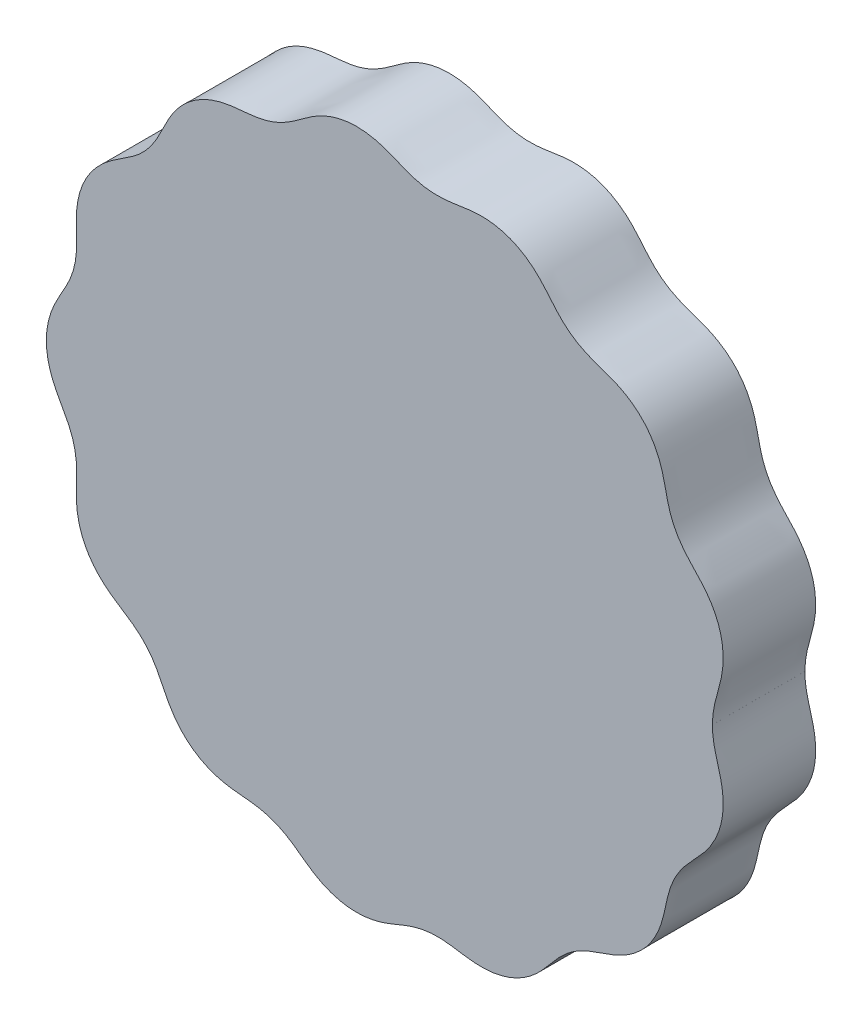
from build123d import *

# Parameters (mm, degrees)
BOSS_EXTRUDE1_DEPTH = 10


with BuildPart() as part:
    # Sketch1 → Boss-Extrude1 (new body)
    with BuildSketch(Plane.XY):
        with BuildLine():
            add(Edge.make_bspline(
                [(35, 0), (35, -0.049310934), (35.000826925, -0.123549041), (35.00358334, -0.260905708), (35.011001765, -0.443866873), (35.02168003, -0.615246909), (35.038822352, -0.820246291), (35.064644021, -1.054225265), (35.104389094, -1.344688824), (35.163372924, -1.692203356), (35.246948475, -2.094474225), (35.358433569, -2.55079151), (35.480657747, -3.004163087), (35.634642353, -3.552998444), (35.812720375, -4.19930319), (35.990573811, -4.949837651), (36.127871975, -5.811262759), (36.182763873, -6.633837248), (36.162995201, -7.409659641), (36.061865068, -8.301480074), (35.875566573, -9.131461485), (35.600274681, -9.936302866), (35.241274265, -10.705998089), (34.906867041, -11.297453714), (34.471313565, -11.949104091), (33.918976342, -12.645450647), (33.24636376, -13.375251593), (32.486194193, -14.16540454), (31.729556574, -15.049165196), (31.046122514, -16.073879372), (30.531343894, -17.194682801), (30.182801414, -18.374420877), (29.944004061, -19.511701744), (29.714374148, -20.584179661), (29.295803858, -22.028148088), (28.462175689, -23.758619693), (27.039511715, -25.411663684), (25.220785614, -26.552164252), (23.632554765, -27.156246313), (22.308241317, -27.596309207), (21.122642737, -28.048878518), (19.998404102, -28.665974936), (18.990362365, -29.469448636), (18.17926367, -30.310264933), (17.506810894, -31.116961152), (16.774956468, -32.003835501), (15.910810759, -32.910989873), (14.603968244, -33.956795362), (12.973977424, -34.758694982), (11.172275828, -35.168753031), (9.452445917, -35.168946806), (8.180676827, -35.007322448), (7.060772067, -34.824590111), (6.077839965, -34.700136729), (4.92526664, -34.654901605), (3.611717568, -34.785681451), (2.34898034, -35.144972521), (1.151468871, -35.643176313), (0.11112449, -36.077304048), (-0.791447095, -36.396834046), (-2.145904167, -36.746914748), (-3.98951328, -36.899860547), (-5.867576144, -36.569631631), (-7.608410698, -35.760261886), (-8.856327652, -34.923335177), (-9.733039987, -34.264800627), (-10.676569221, -33.585684911), (-11.741606641, -32.968376824), (-12.889652144, -32.516976577), (-14.091231923, -32.248027474), (-15.246626723, -32.116451018), (-16.339545407, -32.031422114), (-17.493902089, -31.890723419), (-18.692749484, -31.615334014), (-20.222356026, -31.027358158), (-21.761540735, -30.015940811), (-23.10712517, -28.570457222), (-24.107018635, -26.790727225), (-24.824578895, -25.167993152), (-25.628759836, -23.831611442), (-26.506880009, -22.828807468), (-27.377866045, -22.081755442), (-28.165338381, -21.523253444), (-29.117291307, -20.916900261), (-30.198918832, -20.207011214), (-31.269409842, -19.307551755), (-32.23169961, -18.159970842), (-32.949381231, -16.923233216), (-33.433253432, -15.648473233), (-33.695462895, -14.377812661), (-33.778365664, -13.150774619), (-33.752626295, -11.988801454), (-33.708623439, -10.893020119), (-33.732804458, -9.72956587), (-33.907551836, -8.510065169), (-34.272300595, -7.331799195), (-34.798722456, -6.220199301), (-35.375571547, -5.211611527), (-35.913027045, -4.255901727), (-36.551500379, -2.894765108), (-37.065135004, -1.044163044), (-37.081961548, 0.89324181), (-36.604044439, 2.743519909), (-35.992316197, 4.101262096), (-35.472668892, 5.045134004), (-34.893514715, 6.046838416), (-34.342047055, 7.156554542), (-33.945975846, 8.340330549), (-33.745354875, 9.575816636), (-33.706186832, 10.748767553), (-33.746008177, 11.844740972), (-33.779713502, 13.006251445), (-33.713735097, 14.234046359), (-33.472465306, 15.508780329), (-33.010585942, 16.791612729), (-32.323003578, 18.025433099), (-31.405631869, 19.164101965), (-30.376452217, 20.071047646), (-29.320648284, 20.789362643), (-28.359125221, 21.396424669), (-27.534006018, 21.961691411), (-26.64211418, 22.697115867), (-25.75330467, 23.666754111), (-25.052171961, 24.77089469), (-24.489024343, 25.934085453), (-23.99678217, 26.950841824), (-23.526827657, 27.795754618), (-22.736807023, 28.958901492), (-21.44808756, 30.292839058), (-19.815791171, 31.283258637), (-17.97322752, 31.821967087), (-16.483552658, 32.017713065), (-15.390573104, 32.105317493), (-14.234143791, 32.225772563), (-13.028559404, 32.475991946), (-11.872253588, 32.906226317), (-10.797594574, 33.507307672), (-9.847652658, 34.177822986), (-8.973112624, 34.838578492), (-8.013657651, 35.495538515), (-6.930904053, 36.079170913), (-5.393035326, 36.64508146), (-3.573447131, 36.897950298), (-1.618428071, 36.699809445), (0.303798345, 36.027939455), (1.91709374, 35.289608927), (3.408941719, 34.82571844), (4.736620881, 34.663014931), (5.881346244, 34.685859063), (6.831503524, 34.790818648), (7.94378724, 34.968034923), (9.22904619, 35.153537412), (10.634259731, 35.186555058), (12.124008649, 34.957296868), (13.488997174, 34.496606604), (14.703022495, 33.849803521), (15.74290263, 33.058847151), (16.615744669, 32.18408774), (17.536277891, 31.089607246), (18.448638028, 29.966488187), (19.593575718, 28.921637285), (20.928884162, 28.142170687), (22.10523455, 27.665349127), (23.222010494, 27.293956867), (24.245682165, 26.927775953), (25.608937462, 26.310183857), (27.19294663, 25.232247275), (28.459519151, 23.762767717), (29.293876673, 22.032863207), (29.713266114, 20.589019944), (29.94299122, 19.516612358), (30.181661325, 18.37927563), (30.529578603, 17.199393376), (31.043691667, 16.078271444), (31.726496935, 15.053149854), (32.482801355, 14.169074794), (33.242866577, 13.378834546), (34.030803992, 12.524455234), (34.778526462, 11.54802149), (35.33544245, 10.568085559), (35.717641828, 9.621618689), (35.948917034, 8.804336006), (36.080240473, 8.137642452), (36.162658402, 7.414653672), (36.182876804, 6.638849406), (36.12844469, 5.816231898), (35.99155664, 4.954749604), (35.786940236, 4.089807461), (35.571892127, 3.331954244), (35.387572999, 2.669628976), (35.248069215, 2.099447036), (35.152344118, 1.639434685), (35.086285678, 1.233977549), (35.044236756, 0.884014258), (35.022048081, 0.620168406), (35.011268303, 0.448861583), (35.003741135, 0.265908238), (35.000902541, 0.128549061), (35.000031086, 0.054310816), (35.0000015, 0.004999998)],
                knots=[0.079958514, 0.079958514, 0.079958514, 0.079958514, 0.079958514, 0.080801634, 0.081223194, 0.081644754, 0.082487873, 0.083330993, 0.084174113, 0.085017233, 0.086703472, 0.088389712, 0.090075951, 0.091762191, 0.09344843, 0.096577003, 0.099705577, 0.10283415, 0.105962723, 0.108400074, 0.110837425, 0.115712127, 0.118149426, 0.120586724, 0.123024022, 0.125461321, 0.129398917, 0.133336513, 0.13727411, 0.141211706, 0.146089501, 0.150967295, 0.154905156, 0.158843017, 0.162780878, 0.166718739, 0.176468314, 0.186217728, 0.193522586, 0.197175015, 0.200827444, 0.206276306, 0.211725169, 0.215495006, 0.219264842, 0.223034679, 0.226804515, 0.232014616, 0.237224717, 0.246973949, 0.252616416, 0.258258882, 0.261813328, 0.265367774, 0.268922221, 0.272476667, 0.27835693, 0.284237192, 0.28767307, 0.291108949, 0.294544827, 0.297980705, 0.307730653, 0.31747944, 0.321417046, 0.325354651, 0.329292257, 0.333229863, 0.338108644, 0.342987425, 0.346924808, 0.350862191, 0.354799575, 0.358736958, 0.363611799, 0.368486641, 0.378235835, 0.384925001, 0.391614167, 0.397677439, 0.40374071, 0.407204004, 0.410667298, 0.414130591, 0.417593885, 0.423418295, 0.429242704, 0.434117814, 0.438992924, 0.443866976, 0.448741029, 0.452679303, 0.456617576, 0.46055585, 0.464494124, 0.469372642, 0.474251159, 0.478187931, 0.482124702, 0.486061474, 0.489998246, 0.499748652, 0.509497693, 0.513365606, 0.517233518, 0.521101431, 0.524969343, 0.529986977, 0.535004611, 0.538942566, 0.542880521, 0.546818476, 0.550756431, 0.555630623, 0.560504815, 0.565379892, 0.57025497, 0.575829253, 0.581403536, 0.584991742, 0.588579947, 0.592168153, 0.595756358, 0.601569828, 0.607383298, 0.61085261, 0.614321922, 0.617791235, 0.621260547, 0.631010775, 0.64075969, 0.644697329, 0.648634967, 0.652572605, 0.656510243, 0.661390302, 0.66627036, 0.6702072, 0.67414404, 0.67808088, 0.68201772, 0.686892309, 0.691766898, 0.701516721, 0.708138352, 0.714759983, 0.720890149, 0.727020316, 0.73044972, 0.733879123, 0.737308527, 0.740737931, 0.746630466, 0.752523, 0.757398007, 0.762273014, 0.767232733, 0.772192452, 0.776087607, 0.779982761, 0.78777307, 0.792971131, 0.798169192, 0.802071957, 0.805974723, 0.809877488, 0.813780253, 0.823529654, 0.833279241, 0.837217107, 0.841154973, 0.845092838, 0.849030704, 0.853908475, 0.858786245, 0.862723849, 0.866661453, 0.870599057, 0.874536661, 0.879411256, 0.88428585, 0.886723197, 0.889160545, 0.891597892, 0.894035239, 0.897163822, 0.900292405, 0.903420987, 0.90654957, 0.909922042, 0.911608278, 0.913294514, 0.91498075, 0.916666985, 0.917510103, 0.918353221, 0.91877478, 0.919196339, 0.920039457, 0.920039457, 0.920039457, 0.920039457, 0.920039457], degree=4))
            Line((35.0000015, 0.004999998), (35, 0))
        make_face()
    extrude(amount=BOSS_EXTRUDE1_DEPTH)


solid = part.part
